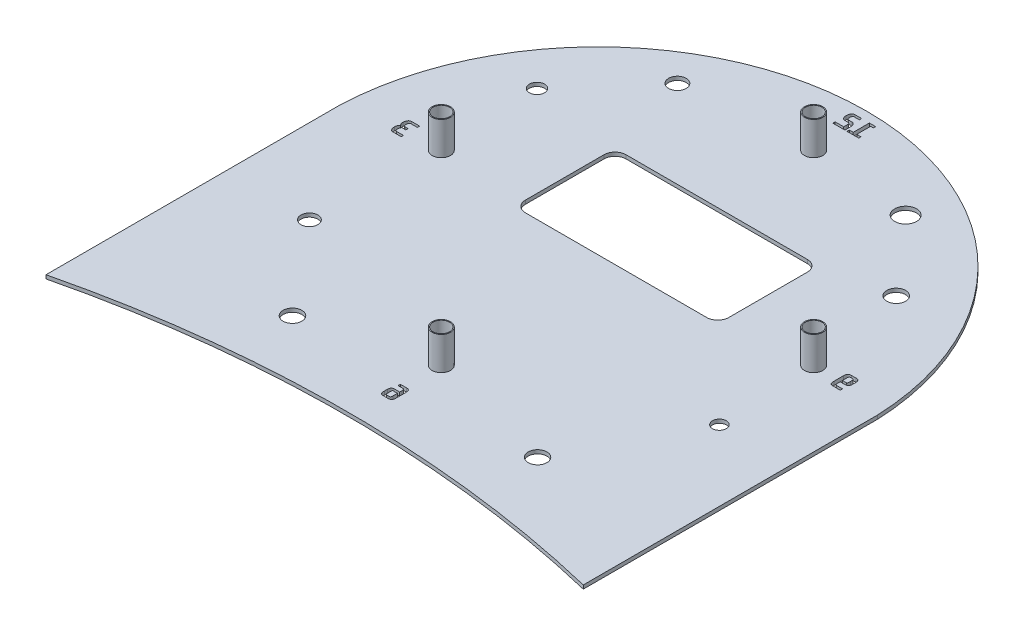
from build123d import *

# Parameters (mm, degrees)
SKETCH2_R             = 2.5
BOSS_EXTRUDE1_DEPTH   = 10
BOSS_EXTRUDE1_2_DEPTH = 10
BOSS_EXTRUDE1_3_DEPTH = 10
BOSS_EXTRUDE1_4_DEPTH = 10
BOSS_EXTRUDE3_DEPTH   = 1
CUT_EXTRUDE1_DEPTH    = 113.227447623
SKETCH6_R             = 2.25
CUT_EXTRUDE2_DEPTH    = 7
SKETCH8_R             = 2.384988422
SKETCH8_R_2           = 2.058423196
SKETCH8_R_3           = 2.555344738
SKETCH8_R_4           = 2.532528703
SKETCH8_R_5           = 1.873919474
SKETCH8_R_6           = 2.291909827
SKETCH8_R_7           = 2.975145152
CUT_EXTRUDE3_DEPTH    = 113.227447623


with BuildPart() as part:
    # Sketch2 → Boss-Extrude1 (new body)
    with BuildSketch(Plane(origin=(0, 0, 0), x_dir=(1, 0, 0), z_dir=(0, 1, 0))):
        with Locations(Location((0, 50.59, 0), (0, 0, 270))):
            Circle(SKETCH2_R)
    extrude(amount=BOSS_EXTRUDE1_DEPTH)



with BuildPart() as body_2:
    # Sketch2 → Boss-Extrude1 2 (new body)
    with BuildSketch(Plane(origin=(0, 0, 0), x_dir=(1, 0, 0), z_dir=(0, 1, 0))):
        with Locations(Location((0, -50.59, 0), (0, 0, 90))):
            Circle(SKETCH2_R)
    extrude(amount=BOSS_EXTRUDE1_2_DEPTH)


with BuildPart() as body_3:
    # Sketch2 → Boss-Extrude1 3 (new body)
    with BuildSketch(Plane(origin=(0, 0, 0), x_dir=(1, 0, 0), z_dir=(0, 1, 0))):
        with Locations(Location((-50.59, 0, 0), (0, 0, 270))):
            Circle(SKETCH2_R)
    extrude(amount=BOSS_EXTRUDE1_3_DEPTH)


with BuildPart() as body_4:
    # Sketch2 → Boss-Extrude1 4 (new body)
    with BuildSketch(Plane(origin=(0, 0, 0), x_dir=(1, 0, 0), z_dir=(0, 1, 0))):
        with Locations(Location((50.59, 0, 0), (0, 0, 90))):
            Circle(SKETCH2_R)
    extrude(amount=BOSS_EXTRUDE1_4_DEPTH)


with BuildPart() as part_1:
    add(part.part)

    add(body_2.part)  # Boss-Extrude3 merges body 2

    add(body_3.part)  # Boss-Extrude3 merges body 3

    add(body_4.part)  # Boss-Extrude3 merges body 4
    # Sketch3 → Boss-Extrude3 (add)
    with BuildSketch(Plane(origin=(0, 0, 0), x_dir=(1, 0, 0), z_dir=(0, 1, 0))):
        with BuildLine():
            Line((-75, -3), (-75, -83))
            ThreePointArc((-75, -83), (-2, -74.296421676), (71, -83))
            Line((71, -83), (71, -3))
            ThreePointArc((71, -3), (-2, 67), (-75, -3))
        make_face()
    extrude(amount=BOSS_EXTRUDE3_DEPTH)

    # Sketch4 → Cut-Extrude1 (cut, through all)
    with BuildSketch(Plane(origin=(0, 1, 0), x_dir=(1, 0, 0), z_dir=(0, 1, 0))):
        with BuildLine():
            Line((-24.427366851, 24.04765378), (24.83486427, 24.04765378))
            ThreePointArc((24.83486427, 24.04765378), (26.956184613, 23.168974123), (27.83486427, 21.04765378))
            Line((27.83486427, 21.04765378), (27.83486427, -0.296868795))
            ThreePointArc((27.83486427, -0.296868795), (26.956184613, -2.418189139), (24.83486427, -3.296868795))
            Line((24.83486427, -3.296868795), (-24.427366851, -3.296868795))
            ThreePointArc((-24.427366851, -3.296868795), (-26.548687195, -2.418189139), (-27.427366851, -0.296868795))
            Line((-27.427366851, -0.296868795), (-27.427366851, 21.04765378))
            ThreePointArc((-27.427366851, 21.04765378), (-26.548687195, 23.168974123), (-24.427366851, 24.04765378))
        make_face()
    extrude(amount=-CUT_EXTRUDE1_DEPTH, mode=Mode.SUBTRACT)

    # Sketch6 → Cut-Extrude2 (cut)
    with BuildSketch(Plane(origin=(0, 10, 0), x_dir=(1, 0, 0), z_dir=(0, 1, 0))):
        with Locations(Location((0, 50.59, 0), (0, 0, 270))):
            Circle(SKETCH6_R)
        with Locations(Location((50.59, 0, 0), (0, 0, 270))):
            Circle(SKETCH6_R)
        with Locations(Location((0, -50.59, 0), (0, 0, 270))):
            Circle(SKETCH6_R)
        with Locations(Location((-50.59, 0, 0), (0, 0, 270))):
            Circle(SKETCH6_R)
    extrude(amount=-CUT_EXTRUDE2_DEPTH, mode=Mode.SUBTRACT)

    # Sketch8 → Cut-Extrude3 (cut, through all)
    with BuildSketch(Plane(origin=(0, 1, 0), x_dir=(1, 0, 0), z_dir=(0, 1, 0))):
        with Locations(Location((-34.241619485, 47.817687309, 0), (0, 0, 270))):
            Circle(SKETCH8_R)
        with Locations(Location((-52.129032649, 27.545285723, 0), (0, 0, 270))):
            Circle(SKETCH8_R_2)
        with Locations(Location((-31.856631064, -59.166079044, 0), (0, 0, 270))):
            Circle(SKETCH8_R_3)
        with Locations(Location((34.752688433, -59.166079044, 0), (0, 0, 270))):
            Circle(SKETCH8_R_4)
        with Locations(Location((51.788320018, -26.798379033, 0), (0, 0, 270))):
            Circle(SKETCH8_R_5)
        with Locations(Location((-52.129032649, -34.29405693, 0), (0, 0, 270))):
            Circle(SKETCH8_R_6)
        with Locations(Location((27.768079483, 47.817687309, 0), (0, 0, 270))):
            Circle(SKETCH8_R_7)
        with Locations(Location((45.485136331, 27.545285723, 0), (0, 0, 270))):
            Circle(SKETCH8_R_3)
        Polygon((1.162791541, 64.572273102), (1.162791541, 60.190987182), (0.101369127, 60.190987182), (0.101369127, 59.572273102), (3.26677861, 59.572273102), (3.26677861, 60.190987182), (2.119149299, 60.190987182), (2.119149299, 63.953559022), (2.857295851, 63.953559022), (2.857295851, 64.572273102), align=None)
        with BuildLine():
            add(Edge.make_bspline(
                [(-2.76680616, 64.572273102), (-2.801344445, 64.571248982), (-2.869864925, 64.569217232), (-2.969733075, 64.547387351), (-3.065840458, 64.514237973), (-3.156249995, 64.465991092), (-3.24150449, 64.406513813), (-3.321249571, 64.336866677), (-3.394278165, 64.256297304), (-3.460381111, 64.165279666), (-3.520233966, 64.065727075), (-3.573717028, 63.958459007), (-3.618265026, 63.842813801), (-3.655955378, 63.720119511), (-3.685083925, 63.59127373), (-3.707027657, 63.457590069), (-3.71950004, 63.319218955), (-3.721335302, 63.225314319), (-3.72226593, 63.177696953)],
                knots=[0, 0, 0, 0, 0.883412923, 1.752602292, 2.606230165, 3.480814088, 4.367780404, 5.264372175, 6.187107428, 7.147158464, 8.141296518, 9.159739572, 10.213422243, 11.312147341, 12.444912722, 13.594550416, 14.780239421, 16, 16, 16, 16], degree=3))
            add(Edge.make_bspline(
                [(-3.72226593, 63.177696953), (-3.721351194, 63.13037701), (-3.719553175, 63.037364271), (-3.706915196, 62.900209225), (-3.685389801, 62.768540013), (-3.655998315, 62.642398648), (-3.618067214, 62.523508922), (-3.574720852, 62.411216827), (-3.522010234, 62.30808602), (-3.464405946, 62.212258112), (-3.398087345, 62.126747924), (-3.326681992, 62.049748633), (-3.247262039, 61.983729605), (-3.162713326, 61.926707391), (-3.070897372, 61.882661575), (-2.974311143, 61.849730681), (-2.872019086, 61.8306835), (-2.802203807, 61.828320384), (-2.76680616, 61.82712224)],
                knots=[0, 0, 0, 0, 1.232681638, 2.422976199, 3.584441407, 4.706062681, 5.793664141, 6.833358588, 7.837712076, 8.80731804, 9.741567724, 10.651784307, 11.537384444, 12.426274237, 13.301653443, 14.18198528, 15.078232656, 16, 16, 16, 16], degree=3))
            Line((-2.76680616, 61.82712224), (-1.816734321, 61.82712224))
            add(Edge.make_bspline(
                [(-1.816734321, 61.82712224), (-1.80111306, 61.826738232), (-1.770787022, 61.825992745), (-1.727071652, 61.816339167), (-1.685970209, 61.802249237), (-1.648136961, 61.781058765), (-1.612832966, 61.755085924), (-1.580971508, 61.722846461), (-1.552030153, 61.684977489), (-1.527286183, 61.640485953), (-1.504874663, 61.590896303), (-1.484836753, 61.535790747), (-1.469105572, 61.474339933), (-1.455831584, 61.407164687), (-1.444869212, 61.334385115), (-1.438114302, 61.255803927), (-1.433527292, 61.171644469), (-1.432780143, 61.113527404), (-1.432395241, 61.083587757)],
                knots=[0, 0, 0, 0, 0.801646385, 1.556260933, 2.291317199, 3.02830444, 3.776298051, 4.538098078, 5.350749551, 6.219335221, 7.149166976, 8.147190876, 9.229802753, 10.406963779, 11.667215597, 13.011854193, 14.460623745, 16, 16, 16, 16], degree=3))
            Line((-1.432395241, 61.083587757), (-1.432395241, 60.190987182))
            Line((-1.432395241, 60.190987182), (-3.741123689, 60.190987182))
            Line((-3.741123689, 60.190987182), (-3.741123689, 59.572273102))
            Line((-3.741123689, 59.572273102), (-0.488609321, 59.572273102))
            Line((-0.488609321, 59.572273102), (-0.488609321, 61.077301838))
            add(Edge.make_bspline(
                [(-0.488609321, 61.077301838), (-0.489222559, 61.124918085), (-0.490431673, 61.218802605), (-0.502279812, 61.357088237), (-0.522179986, 61.490159809), (-0.54863366, 61.617841343), (-0.583604678, 61.738767777), (-0.625521468, 61.852124835), (-0.674865772, 61.956852226), (-0.731889705, 62.052617116), (-0.794936703, 62.139868733), (-0.8659229, 62.216435955), (-0.94151739, 62.284862164), (-1.024286687, 62.342539361), (-1.113814273, 62.388876942), (-1.209867511, 62.422303153), (-1.312701028, 62.442693304), (-1.383508648, 62.44477083), (-1.419823402, 62.44583632)],
                knots=[0, 0, 0, 0, 1.238190693, 2.441329258, 3.606154233, 4.736011148, 5.829948853, 6.876865924, 7.876278487, 8.836223236, 9.772031656, 10.670133808, 11.546790952, 12.419255612, 13.286215269, 14.160241466, 15.056452164, 16, 16, 16, 16], degree=3))
            Line((-1.419823402, 62.44583632), (-2.357323402, 62.44583632))
            add(Edge.make_bspline(
                [(-2.357323402, 62.44583632), (-2.374147064, 62.446525508), (-2.406897825, 62.447867156), (-2.454538601, 62.45844699), (-2.500190275, 62.474085023), (-2.541949646, 62.49896539), (-2.581653792, 62.529197467), (-2.618216139, 62.566256618), (-2.652733312, 62.609800143), (-2.69464321, 62.678098282), (-2.739367508, 62.774731881), (-2.776299959, 62.903770063), (-2.800473763, 63.045687913), (-2.802546505, 63.144962623), (-2.803623689, 63.196554711)],
                knots=[0, 0, 0, 0, 0.626403645, 1.219425088, 1.812341563, 2.417107145, 3.021872728, 3.668806802, 4.351870119, 5.088677919, 6.651105758, 8.303298396, 10.078860628, 12, 12, 12, 12], degree=3))
            add(Edge.make_bspline(
                [(-2.803623689, 63.196554711), (-2.802531829, 63.248145278), (-2.80042459, 63.347712681), (-2.776285871, 63.490221767), (-2.739396938, 63.620156382), (-2.6945106, 63.71762953), (-2.652663743, 63.786784412), (-2.618614399, 63.83142668), (-2.580962418, 63.868102981), (-2.542875252, 63.90088137), (-2.499634653, 63.923877144), (-2.454801778, 63.941297157), (-2.406854926, 63.951429473), (-2.374132506, 63.952836334), (-2.357323402, 63.953559022)],
                knots=[0, 0, 0, 0, 1.911211498, 3.688549631, 5.342851106, 6.907278215, 7.649714243, 8.337984846, 8.981575758, 9.596983535, 10.193172533, 10.786876536, 11.376833422, 12, 12, 12, 12], degree=3))
            Line((-2.357323402, 63.953559022), (-0.954665356, 63.953559022))
            Line((-0.954665356, 63.953559022), (-0.954665356, 64.572273102))
            Line((-0.954665356, 64.572273102), (-2.76680616, 64.572273102))
        make_face()
        with BuildLine():
            add(Edge.make_bspline(
                [(-61.407365743, 2.732930449), (-61.442772605, 2.731789871), (-61.512956102, 2.729529017), (-61.615548355, 2.709484332), (-61.713066342, 2.675402909), (-61.805737103, 2.629604893), (-61.892308443, 2.571884279), (-61.973734849, 2.504868707), (-62.046774751, 2.426385879), (-62.113809713, 2.338520549), (-62.173279761, 2.241656055), (-62.227069523, 2.136927361), (-62.271368211, 2.023233632), (-62.309088946, 1.902350373), (-62.338318488, 1.77500716), (-62.360145143, 1.642494433), (-62.37263598, 1.505022303), (-62.374468196, 1.411714417), (-62.375397352, 1.364395967)],
                knots=[0, 0, 0, 0, 0.910775932, 1.805340438, 2.677662487, 3.563222759, 4.458616409, 5.350422625, 6.271568503, 7.211597251, 8.190846648, 9.193578845, 10.238039795, 11.327376783, 12.450627843, 13.598243416, 14.782017202, 16, 16, 16, 16], degree=3))
            add(Edge.make_bspline(
                [(-62.375397352, 1.364395967), (-62.374354023, 1.307162718), (-62.372337053, 1.196519063), (-62.352204577, 1.036241273), (-62.319466639, 0.888190146), (-62.273765149, 0.751293526), (-62.213246566, 0.627417525), (-62.141038577, 0.514157315), (-62.054415495, 0.413448432), (-61.987077013, 0.356597559), (-61.953342755, 0.328117231)],
                knots=[0, 0, 0, 0, 1.183392342, 2.287741059, 3.334728265, 4.315684044, 5.26550679, 6.179184378, 7.087834151, 8, 8, 8, 8], degree=3))
            add(Edge.make_bspline(
                [(-61.953342755, 0.328117231), (-61.971027602, 0.31595619), (-62.007417968, 0.290932242), (-62.057525646, 0.243985103), (-62.106880265, 0.190571567), (-62.169885283, 0.10677412), (-62.243255465, -0.010550961), (-62.316719583, -0.166320504), (-62.37692211, -0.334167052), (-62.420397672, -0.509324312), (-62.451389234, -0.686434116), (-62.454621753, -0.80501761), (-62.456216318, -0.863513516)],
                knots=[0, 0, 0, 0, 0.481349107, 0.990478989, 1.537594596, 2.113006566, 3.342087074, 4.637932592, 5.973155259, 7.339337083, 8.687524853, 10, 10, 10, 10], degree=3))
            add(Edge.make_bspline(
                [(-62.456216318, -0.863513516), (-62.455386615, -0.912336874), (-62.45375449, -1.008378345), (-62.439907257, -1.149683111), (-62.417763493, -1.285674121), (-62.386123744, -1.415426494), (-62.347915271, -1.538612929), (-62.30195554, -1.653753032), (-62.249887659, -1.761005297), (-62.191662339, -1.860236001), (-62.126518494, -1.950567604), (-62.052729733, -2.029756274), (-61.973828708, -2.101086512), (-61.886641132, -2.159623753), (-61.794898942, -2.208098312), (-61.698196189, -2.242469141), (-61.597369309, -2.26257166), (-61.52898162, -2.265561012), (-61.494470628, -2.267069551)],
                knots=[0, 0, 0, 0, 1.242606327, 2.444357468, 3.610605161, 4.747202764, 5.841322862, 6.89122067, 7.899940925, 8.873513482, 9.816919495, 10.728270463, 11.624298118, 12.518282303, 13.394157939, 14.259362339, 15.121608997, 16, 16, 16, 16], degree=3))
            Line((-61.494470628, -2.267069551), (-59.216273789, -2.267069551))
            Line((-59.216273789, -2.267069551), (-59.216273789, -1.64835547))
            Line((-59.216273789, -1.64835547), (-61.091273789, -1.64835547))
            add(Edge.make_bspline(
                [(-61.091273789, -1.64835547), (-61.107516004, -1.647731703), (-61.139473944, -1.646504388), (-61.185836115, -1.634724424), (-61.230497036, -1.61850791), (-61.271054582, -1.591962855), (-61.310493752, -1.560368848), (-61.346850126, -1.520877995), (-61.380256735, -1.474099046), (-61.422961107, -1.401932829), (-61.46766419, -1.297225658), (-61.504231011, -1.155873985), (-61.528266934, -0.997528037), (-61.530248694, -0.886060398), (-61.531288157, -0.827593976)],
                knots=[0, 0, 0, 0, 0.569391451, 1.12032616, 1.672964226, 2.230284484, 2.813301044, 3.445717575, 4.108276049, 4.829640806, 6.388522522, 8.08734975, 9.947757181, 12, 12, 12, 12], degree=3))
            add(Edge.make_bspline(
                [(-61.531288157, -0.827593976), (-61.529809409, -0.773315118), (-61.526943496, -0.668119023), (-61.502903673, -0.517041598), (-61.467180132, -0.37997183), (-61.422093049, -0.278521364), (-61.380983746, -0.207681475), (-61.347865314, -0.161093547), (-61.310500336, -0.121923904), (-61.272317622, -0.087026664), (-61.230463036, -0.059793873), (-61.186351097, -0.039821436), (-61.139535103, -0.027448832), (-61.107512557, -0.026281964), (-61.091273789, -0.02569024)],
                knots=[0, 0, 0, 0, 1.948076852, 3.775504575, 5.481032268, 7.021075351, 7.743779428, 8.421087952, 9.067583505, 9.684444277, 10.274790727, 10.852173998, 11.417932608, 12, 12, 12, 12], degree=3))
            Line((-61.091273789, -0.02569024), (-60.178019479, -0.02569024))
            Line((-60.178019479, -0.02569024), (-60.178019479, 0.59302384))
            Line((-60.178019479, 0.59302384), (-61.010454824, 0.59302384))
            add(Edge.make_bspline(
                [(-61.010454824, 0.59302384), (-61.027554295, 0.593462883), (-61.061105922, 0.594324348), (-61.109837872, 0.603392417), (-61.155281326, 0.618998439), (-61.197785198, 0.639848465), (-61.23782516, 0.665813742), (-61.27399341, 0.698933583), (-61.307168935, 0.737516593), (-61.336975368, 0.782295679), (-61.363802282, 0.832483318), (-61.387054601, 0.888463699), (-61.406882557, 0.95002272), (-61.422762184, 1.017320308), (-61.435254913, 1.090204497), (-61.444116134, 1.168753416), (-61.44951046, 1.252969167), (-61.450143283, 1.311106952), (-61.450469191, 1.341048265)],
                knots=[0, 0, 0, 0, 0.843430555, 1.654932301, 2.435297777, 3.208495403, 3.987180262, 4.782374215, 5.620611183, 6.493555423, 7.432304167, 8.42574729, 9.481833166, 10.621546881, 11.836195749, 13.130222216, 14.522046972, 16, 16, 16, 16], degree=3))
            add(Edge.make_bspline(
                [(-61.450469191, 1.341048265), (-61.449275935, 1.399495849), (-61.447026916, 1.509656314), (-61.425740601, 1.664260444), (-61.390914898, 1.798327758), (-61.34754068, 1.894468222), (-61.307782485, 1.960485098), (-61.273648287, 2.000970649), (-61.238251469, 2.036944188), (-61.197768311, 2.064453876), (-61.155765746, 2.087759809), (-61.10966691, 2.102551679), (-61.061238234, 2.113251216), (-61.027579631, 2.113890907), (-61.010454824, 2.114216369)],
                knots=[0, 0, 0, 0, 2.119697477, 3.995149981, 5.649785381, 7.127534701, 7.805636685, 8.438383571, 9.045149214, 9.629735126, 10.207929712, 10.781515463, 11.380060031, 12, 12, 12, 12], degree=3))
            Line((-61.010454824, 2.114216369), (-59.216273789, 2.114216369))
            Line((-59.216273789, 2.114216369), (-59.216273789, 2.732930449))
            Line((-59.216273789, 2.732930449), (-61.407365743, 2.732930449))
        make_face()
        with BuildLine():
            Line((-1.061604951, -60.639619046), (-1.061604951, -61.258333127))
            Line((-1.061604951, -61.258333127), (0.285377808, -61.258333127))
            add(Edge.make_bspline(
                [(0.285377808, -61.258333127), (0.317859504, -61.260001909), (0.378854343, -61.263135584), (0.46344084, -61.287565219), (0.531335065, -61.332449054), (0.573381552, -61.384792854), (0.597532827, -61.435761931), (0.613926847, -61.482381287), (0.626472415, -61.537020579), (0.638794604, -61.599172456), (0.64597951, -61.669521911), (0.65225206, -61.747654142), (0.65719357, -61.833884356), (0.657161692, -61.894101525), (0.657145049, -61.925538586)],
                knots=[0, 0, 0, 0, 1.330604464, 2.498638161, 3.560222214, 4.61590636, 5.202975443, 5.866465476, 6.637102745, 7.498483031, 8.461730792, 9.532490332, 10.711808402, 12, 12, 12, 12], degree=3))
            Line((0.657145049, -61.925538586), (0.657145049, -62.549640598))
            Line((0.657145049, -62.549640598), (-0.832617882, -62.549640598))
            add(Edge.make_bspline(
                [(-0.832617882, -62.549640598), (-0.864682636, -62.550553021), (-0.9272702, -62.552333992), (-1.018288031, -62.564717397), (-1.103379698, -62.586576177), (-1.183159983, -62.616090169), (-1.257257391, -62.654783253), (-1.324947724, -62.702797716), (-1.386469576, -62.759159929), (-1.44217277, -62.823029494), (-1.491724845, -62.894461581), (-1.534641892, -62.972446339), (-1.570649732, -63.056780136), (-1.600339951, -63.147208126), (-1.623601823, -63.243890913), (-1.639384336, -63.346937807), (-1.649479604, -63.455809986), (-1.650869945, -63.530520067), (-1.651583399, -63.568857552)],
                knots=[0, 0, 0, 0, 1.039328235, 2.028676792, 2.969994572, 3.881899197, 4.780282589, 5.671353161, 6.564218013, 7.478802897, 8.412791229, 9.376886319, 10.359168011, 11.380910595, 12.458747086, 13.578565012, 14.757440406, 16, 16, 16, 16], degree=3))
            Line((-1.651583399, -63.568857552), (-1.651583399, -64.414762724))
            add(Edge.make_bspline(
                [(-1.651583399, -64.414762724), (-1.650826521, -64.471344628), (-1.649375594, -64.579811402), (-1.640332008, -64.735216016), (-1.622003045, -64.875748056), (-1.598679029, -65.002429642), (-1.566373802, -65.11556976), (-1.526151972, -65.216508682), (-1.476639163, -65.305500537), (-1.41792132, -65.382626915), (-1.350237339, -65.448312114), (-1.27426865, -65.503800708), (-1.188464397, -65.547660991), (-1.094166329, -65.582919965), (-0.989845183, -65.608694799), (-0.874967585, -65.62579884), (-0.749069826, -65.638133681), (-0.661135758, -65.639110125), (-0.615304664, -65.639619046)],
                knots=[0, 0, 0, 0, 1.442765826, 2.765763374, 3.966095796, 5.054260936, 6.047033607, 6.961151509, 7.818823609, 8.635480336, 9.423460715, 10.215753575, 11.024778667, 11.872477496, 12.77763073, 13.758836494, 14.831909207, 16, 16, 16, 16], degree=3))
            Line((-0.615304664, -65.639619046), (0.576326084, -65.639619046))
            add(Edge.make_bspline(
                [(0.576326084, -65.639619046), (0.621241252, -65.638946729), (0.707619567, -65.637653768), (0.831981459, -65.627384847), (0.945510832, -65.60792991), (1.049937352, -65.584142166), (1.143882274, -65.54867262), (1.229034222, -65.504688692), (1.304111726, -65.449181122), (1.370576014, -65.383785092), (1.42816143, -65.307109114), (1.475145249, -65.217790518), (1.515714977, -65.117691824), (1.547931586, -65.005112926), (1.571792922, -64.879137439), (1.588070922, -64.738978887), (1.599181672, -64.584359774), (1.60033126, -64.476446227), (1.600930969, -64.420150655)],
                knots=[0, 0, 0, 0, 1.153745744, 2.218818673, 3.200984114, 4.111039993, 4.965062417, 5.773312264, 6.565306797, 7.353672684, 8.161007703, 9.017656619, 9.938593583, 10.931385752, 12.020119487, 13.228452366, 14.55415872, 16, 16, 16, 16], degree=3))
            Line((1.600930969, -64.420150655), (1.600930969, -61.852801517))
            add(Edge.make_bspline(
                [(1.600930969, -61.852801517), (1.600340407, -61.79650517), (1.599211486, -61.688888789), (1.588050776, -61.534873293), (1.571910022, -61.395882519), (1.547813112, -61.271143805), (1.515719619, -61.159738217), (1.475187532, -61.060498148), (1.427905774, -60.971971146), (1.370598728, -60.895445301), (1.304113141, -60.830037411), (1.229005537, -60.774636659), (1.144093435, -60.730268989), (1.049582887, -60.69654081), (0.945699219, -60.670892316), (0.831946224, -60.65198173), (0.707629558, -60.641547893), (0.621244669, -60.6402789), (0.576326084, -60.639619046)],
                knots=[0, 0, 0, 0, 1.450598497, 2.772971403, 3.977622775, 5.054797434, 6.043450196, 6.960272824, 7.812962795, 8.622954169, 9.413913998, 10.208514412, 11.019423624, 11.873577921, 12.788483764, 13.7738808, 14.842458114, 16, 16, 16, 16], degree=3))
            Line((0.576326084, -60.639619046), (-1.061604951, -60.639619046))
        make_face()
        with BuildLine():
            add(Edge.make_bspline(
                [(0.657145049, -64.349209563), (0.657083772, -64.380944019), (0.656966375, -64.441741883), (0.653051743, -64.528559643), (0.648153929, -64.607095433), (0.640036381, -64.677210559), (0.629945682, -64.739534533), (0.614976823, -64.794274728), (0.598691292, -64.842372483), (0.572970789, -64.896074241), (0.530176511, -64.949997127), (0.462120234, -64.995537594), (0.377854669, -65.016506093), (0.317791578, -65.019363131), (0.285377808, -65.020904966)],
                knots=[0, 0, 0, 0, 1.291042637, 2.473419913, 3.535518923, 4.491792015, 5.344764261, 6.101046511, 6.798240471, 7.408290884, 8.51719159, 9.554205062, 10.680097336, 12, 12, 12, 12], degree=3))
            Line((0.285377808, -65.020904966), (-0.353990008, -65.020904966))
            add(Edge.make_bspline(
                [(-0.353990008, -65.020904966), (-0.38318037, -65.019722393), (-0.43828331, -65.017490039), (-0.514923661, -64.995706534), (-0.579395818, -64.959210227), (-0.62148253, -64.915554648), (-0.649324809, -64.874017944), (-0.665788611, -64.835356244), (-0.681039354, -64.791631049), (-0.693726446, -64.742110021), (-0.702061094, -64.686411153), (-0.709716468, -64.625081211), (-0.712598318, -64.557565967), (-0.713576019, -64.510846816), (-0.714083399, -64.486601805)],
                knots=[0, 0, 0, 0, 1.414014997, 2.669250323, 3.827955494, 4.968299414, 5.576749619, 6.246464138, 6.999969569, 7.824497951, 8.722544329, 9.731701722, 10.82286137, 12, 12, 12, 12], degree=3))
            Line((-0.714083399, -64.486601805), (-0.714083399, -63.591307264))
            add(Edge.make_bspline(
                [(-0.714083399, -63.591307264), (-0.713291398, -63.558366066), (-0.711804915, -63.496539725), (-0.70371767, -63.410102878), (-0.687926464, -63.336715977), (-0.665779817, -63.276164707), (-0.637342033, -63.227964228), (-0.601192809, -63.192606331), (-0.557106927, -63.171572368), (-0.525420666, -63.169437819), (-0.50934202, -63.168354678)],
                knots=[0, 0, 0, 0, 1.517420876, 2.8480014, 3.991875943, 4.964812884, 5.806526542, 6.547624034, 7.263016891, 8, 8, 8, 8], degree=3))
            Line((-0.50934202, -63.168354678), (0.657145049, -63.168354678))
            Line((0.657145049, -63.168354678), (0.657145049, -64.349209563))
        make_face(mode=Mode.SUBTRACT)
        with BuildLine():
            add(Edge.make_bspline(
                [(58.163910223, 2.732930449), (58.11808838, 2.73235271), (58.029873949, 2.73124047), (57.903167435, 2.719712509), (57.787326563, 2.699874702), (57.681935021, 2.673416951), (57.585722286, 2.638744068), (57.500131999, 2.592240418), (57.422674191, 2.537581434), (57.355340599, 2.471449837), (57.296245607, 2.395314965), (57.246793037, 2.307136466), (57.206536852, 2.207110167), (57.174354104, 2.095129233), (57.1510529, 1.970550411), (57.132660877, 1.833624851), (57.123551674, 1.683305152), (57.122101252, 1.578725152), (57.121345568, 1.524237921)],
                knots=[0, 0, 0, 0, 1.176173653, 2.264323826, 3.262399436, 4.190605516, 5.0513699, 5.879973481, 6.683979628, 7.477412609, 8.293629253, 9.150542937, 10.063869051, 11.056129081, 12.136736463, 13.314891749, 14.601031619, 16, 16, 16, 16], degree=3))
            Line((57.121345568, 1.524237921), (57.121345568, -1.052091102))
            add(Edge.make_bspline(
                [(57.121345568, -1.052091102), (57.12208109, -1.108375205), (57.12348295, -1.215649402), (57.132723234, -1.369543213), (57.150748546, -1.508021358), (57.174195117, -1.632622277), (57.206845125, -1.743557707), (57.246978592, -1.843264212), (57.296228468, -1.93210921), (57.355307484, -2.009170803), (57.422689739, -2.076073653), (57.499624547, -2.131994484), (57.585867131, -2.177211244), (57.681831341, -2.211420676), (57.787524989, -2.235440174), (57.903179447, -2.254871443), (58.029925949, -2.26509347), (58.118097121, -2.266393872), (58.163910223, -2.267069551)],
                knots=[0, 0, 0, 0, 1.437837729, 2.740434309, 3.935442916, 5.003141779, 5.975761353, 6.884518784, 7.743805759, 8.562000136, 9.356815279, 10.161281736, 10.982151415, 11.835977777, 12.755861699, 13.747678095, 14.829709858, 16, 16, 16, 16], degree=3))
            Line((58.163910223, -2.267069551), (60.088299591, -2.267069551))
            Line((60.088299591, -2.267069551), (60.088299591, -1.64835547))
            Line((60.088299591, -1.64835547), (58.474614246, -1.64835547))
            add(Edge.make_bspline(
                [(58.474614246, -1.64835547), (58.442240169, -1.64693869), (58.382459549, -1.644322524), (58.310554939, -1.629022596), (58.262945018, -1.605108461), (58.23125615, -1.582594173), (58.203101766, -1.554307199), (58.178661981, -1.520207517), (58.156703406, -1.480303251), (58.13969276, -1.433425442), (58.123594999, -1.380916664), (58.113730548, -1.321112836), (58.1057305, -1.253979657), (58.099400975, -1.178509852), (58.095940578, -1.094330144), (58.09575834, -1.035331892), (58.095663097, -1.004497712)],
                knots=[0, 0, 0, 0, 1.572112801, 2.902997967, 3.519749629, 4.144142002, 4.78056874, 5.445496504, 6.173077828, 6.981861885, 7.859259726, 8.83307814, 9.915239253, 11.138879538, 12.504696268, 14, 14, 14, 14], degree=3))
            Line((58.095663097, -1.004497712), (58.095663097, -0.299576735))
            Line((58.095663097, -0.299576735), (59.56028235, -0.299576735))
            add(Edge.make_bspline(
                [(59.56028235, -0.299576735), (59.593565067, -0.298812954), (59.658025915, -0.297333689), (59.751476718, -0.283091025), (59.838771033, -0.262316858), (59.919630985, -0.231439369), (59.993874427, -0.191646549), (60.061877955, -0.143090004), (60.122143576, -0.084452412), (60.177227239, -0.019226344), (60.224407386, 0.054447271), (60.266710886, 0.132887111), (60.301732359, 0.217240698), (60.330508495, 0.306447483), (60.352792039, 0.401058898), (60.369146105, 0.500941087), (60.377691611, 0.606345167), (60.379315086, 0.678319416), (60.380145856, 0.715150277)],
                knots=[0, 0, 0, 0, 1.08007958, 2.091861781, 3.063191448, 3.989304036, 4.893893583, 5.792246496, 6.692910423, 7.617644599, 8.558585647, 9.528357604, 10.50864427, 11.52000613, 12.569199608, 13.662279829, 14.803735381, 16, 16, 16, 16], degree=3))
            Line((60.380145856, 0.715150277), (60.380145856, 1.519747978))
            add(Edge.make_bspline(
                [(60.380145856, 1.519747978), (60.379450296, 1.574243337), (60.378111462, 1.679137646), (60.368155074, 1.829870543), (60.352719698, 1.967637821), (60.329408812, 2.092210015), (60.299576172, 2.204771755), (60.259903991, 2.305036794), (60.212585104, 2.393783514), (60.156204227, 2.4711414), (60.089296634, 2.536130082), (60.014634074, 2.592616052), (59.929443703, 2.637557144), (59.835354902, 2.673593034), (59.730646961, 2.700027729), (59.615680649, 2.719627247), (59.489281731, 2.731286837), (59.401363704, 2.732367309), (59.355540971, 2.732930449)],
                knots=[0, 0, 0, 0, 1.404245592, 2.702934251, 3.891280875, 4.97450986, 5.966322219, 6.88736731, 7.746786793, 8.552128268, 9.343043883, 10.142192186, 10.956680345, 11.816203675, 12.732975052, 13.734815619, 14.819389566, 16, 16, 16, 16], degree=3))
            Line((59.355540971, 2.732930449), (58.163910223, 2.732930449))
        make_face()
        with BuildLine():
            add(Edge.make_bspline(
                [(59.058306775, 2.114216369), (59.076921323, 2.113904349), (59.112944633, 2.11330052), (59.163897405, 2.102953362), (59.21026488, 2.087924857), (59.251281011, 2.065274799), (59.286942336, 2.034784845), (59.318174751, 1.996807397), (59.344911008, 1.950668701), (59.36719507, 1.895847394), (59.385748866, 1.832919549), (59.400744192, 1.761090216), (59.413310003, 1.68049184), (59.421954829, 1.590222015), (59.427622036, 1.490145691), (59.433608819, 1.37942551), (59.435782875, 1.257842992), (59.436162675, 1.173124199), (59.436359936, 1.129122978)],
                knots=[0, 0, 0, 0, 0.754790739, 1.460688833, 2.102860759, 2.728825679, 3.350048372, 3.997722765, 4.717210034, 5.507598175, 6.396263731, 7.378879318, 8.486424444, 9.708470983, 11.060891991, 12.558327977, 14.212465461, 16, 16, 16, 16], degree=3))
            add(Edge.make_bspline(
                [(59.436359936, 1.129122978), (59.436137528, 1.095597141), (59.435708568, 1.030935656), (59.433848801, 0.937539889), (59.431401666, 0.851005686), (59.427145004, 0.771031877), (59.420295991, 0.697781021), (59.414705675, 0.631184747), (59.40658653, 0.571550772), (59.396775416, 0.518491039), (59.385634517, 0.471727555), (59.371234731, 0.431186398), (59.353418955, 0.396978517), (59.332705464, 0.368624557), (59.308964978, 0.345996465), (59.281270761, 0.330977345), (59.251274059, 0.320078023), (59.229923626, 0.31945483), (59.219046718, 0.319137346)],
                knots=[0, 0, 0, 0, 1.779254049, 3.431658136, 4.957416704, 6.373461233, 7.680815136, 8.861594546, 9.919744809, 10.873143353, 11.724615494, 12.468358517, 13.150513551, 13.76370454, 14.325793163, 14.873557252, 15.426137447, 16, 16, 16, 16], degree=3))
            Line((59.219046718, 0.319137346), (58.095663097, 0.319137346))
            Line((58.095663097, 0.319137346), (58.095663097, 1.436235047))
            add(Edge.make_bspline(
                [(58.095663097, 1.436235047), (58.095630538, 1.467972598), (58.095568452, 1.52849127), (58.100680653, 1.615304995), (58.106551791, 1.694110608), (58.114929479, 1.765325536), (58.128085491, 1.828370863), (58.141547568, 1.883920715), (58.158830261, 1.931449727), (58.184221615, 1.983394789), (58.226736134, 2.037326827), (58.295100902, 2.083943962), (58.380383623, 2.10974199), (58.44181061, 2.112658745), (58.474614246, 2.114216369)],
                knots=[0, 0, 0, 0, 1.282698481, 2.445910484, 3.514108405, 4.477667304, 5.341469094, 6.116272138, 6.786179313, 7.381439824, 8.449157887, 9.51982025, 10.675518416, 12, 12, 12, 12], degree=3))
            Line((58.474614246, 2.114216369), (59.058306775, 2.114216369))
        make_face(mode=Mode.SUBTRACT)
    extrude(amount=-CUT_EXTRUDE3_DEPTH, mode=Mode.SUBTRACT)


with BuildPart() as cut_extrude3_piece_1:
    # of the separate pieces the step leaves, piece 1, a body of its own (cut_extrude3_pieces)
    add(part_1.part.solids().sort_by_distance((71, 0, 83))[0])


with BuildPart() as cut_extrude3_piece_2:
    # of the separate pieces the step leaves, piece 2, a body of its own (cut_extrude3_pieces)
    add(part_1.part.solids().sort_by_distance((0.285377808, 0, 65.020904966))[0])


with BuildPart() as cut_extrude3_piece_3:
    # of the separate pieces the step leaves, piece 3, a body of its own (cut_extrude3_pieces)
    add(part_1.part.solids().sort_by_distance((59.219046718, 0, -0.319137346))[0])


solid = Compound([cut_extrude3_piece_1.part, cut_extrude3_piece_2.part, cut_extrude3_piece_3.part])
